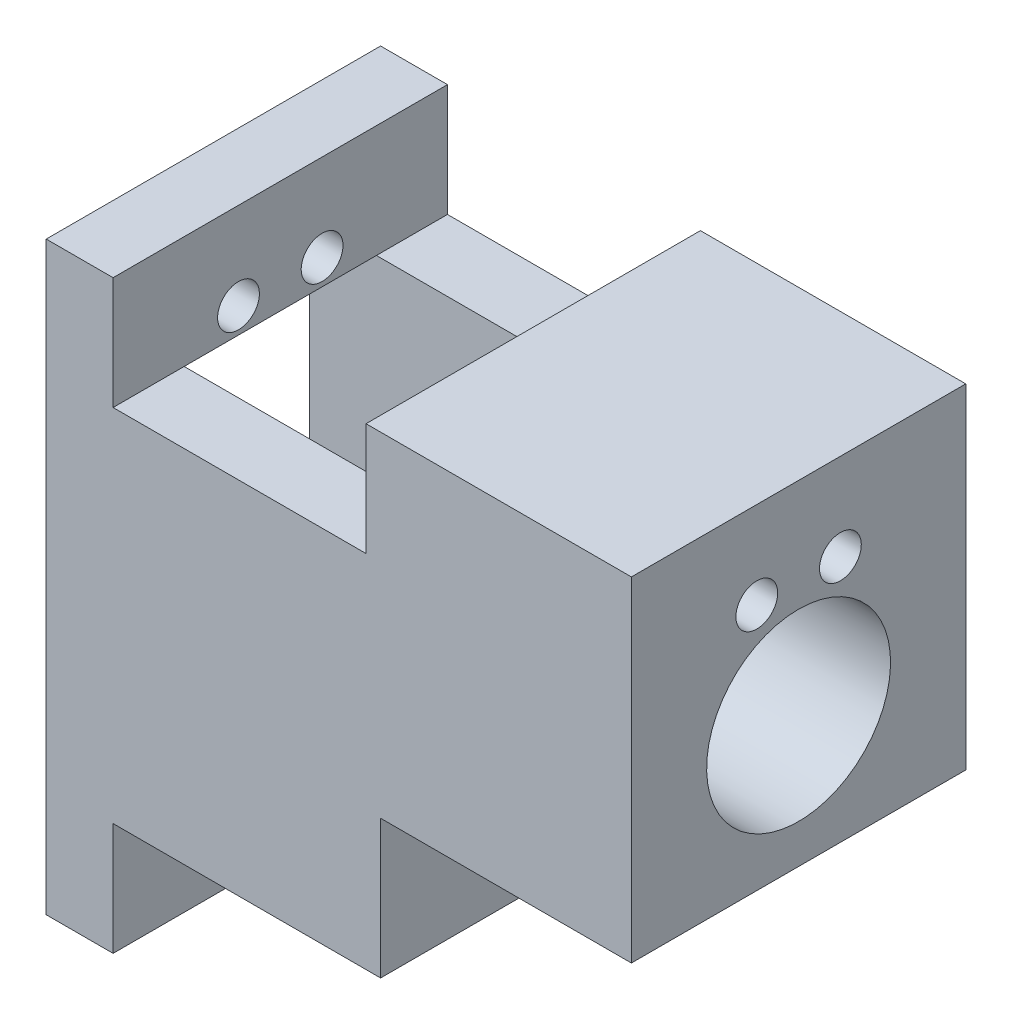
from build123d import *

# Parameters (mm, degrees)
BOSS_EXTRUDE1_DEPTH = 40
SKETCH3_W           = 11.5
SKETCH3_H           = 44
CUT_EXTRUDE1_DEPTH  = 30
SKETCH4_W           = 30.254833929
SKETCH4_H           = 40
CUT_EXTRUDE2_DEPTH  = 13.45
SKETCH5_W           = 32
SKETCH5_H           = 40
CUT_EXTRUDE3_DEPTH  = 13.45
SKETCH6_R           = 2.5
CUT_EXTRUDE4_DEPTH  = 100
CUT_EXTRUDE5_DEPTH  = 28.12


with BuildPart() as part:
    # Sketch1 → Boss-Extrude1 (new body)
    with BuildSketch(Plane.XY):
        Polygon((0, 0), (-70, 0), (-70, -70), (-30, -70), (-30, -40), (0, -40), align=None)
    extrude(amount=BOSS_EXTRUDE1_DEPTH)

    # Sketch3 → Cut-Extrude1 (cut)
    with BuildSketch(Plane.ZY.offset(70)):
        with Locations((14.25, -35.45)):
            Rectangle(SKETCH3_W, SKETCH3_H)
        with Locations((25.75, -35.45)):
            Rectangle(SKETCH3_W, SKETCH3_H)
    extrude(amount=-CUT_EXTRUDE1_DEPTH, mode=Mode.SUBTRACT)

    # Sketch4 → Cut-Extrude2 (cut)
    with BuildSketch(Plane(origin=(0, 0, 0), x_dir=(1, 0, 0), z_dir=(0, 1, 0))):
        with Locations((-46.872583036, -20)):
            Rectangle(SKETCH4_W, SKETCH4_H)
    extrude(amount=-CUT_EXTRUDE2_DEPTH, mode=Mode.SUBTRACT)

    # Sketch5 → Cut-Extrude3 (cut)
    with BuildSketch(Plane.XZ.offset(70)):
        with Locations((-46, 20)):
            Rectangle(SKETCH5_W, SKETCH5_H)
    extrude(amount=-CUT_EXTRUDE3_DEPTH, mode=Mode.SUBTRACT)

    # Sketch6 → Cut-Extrude4 (cut)
    with BuildSketch(Plane.ZY.offset(70)):
        with Locations((15, -10.4)):
            Circle(SKETCH6_R)
        with Locations((25, -10.4)):
            Circle(SKETCH6_R)
        with Locations((25, -60.5)):
            Circle(SKETCH6_R)
        with Locations((15, -60.5)):
            Circle(SKETCH6_R)
    extrude(amount=-CUT_EXTRUDE4_DEPTH, mode=Mode.SUBTRACT)

    # Sketch7 → Cut-Extrude5 (cut)
    with BuildSketch(Plane(origin=(0, 0, 0), x_dir=(0, 0, -1), z_dir=(1, 0, 0))):
        with BuildLine():
            ThreePointArc((-31, -24.34), (-20, -35.34), (-9, -24.34))
            Line((-9, -24.34), (-31, -24.34))
        make_face()
        with BuildLine():
            Line((-31, -24.34), (-9, -24.34))
            ThreePointArc((-9, -24.34), (-20, -13.34), (-31, -24.34))
        make_face()
    extrude(amount=-CUT_EXTRUDE5_DEPTH, mode=Mode.SUBTRACT)


solid = part.part
